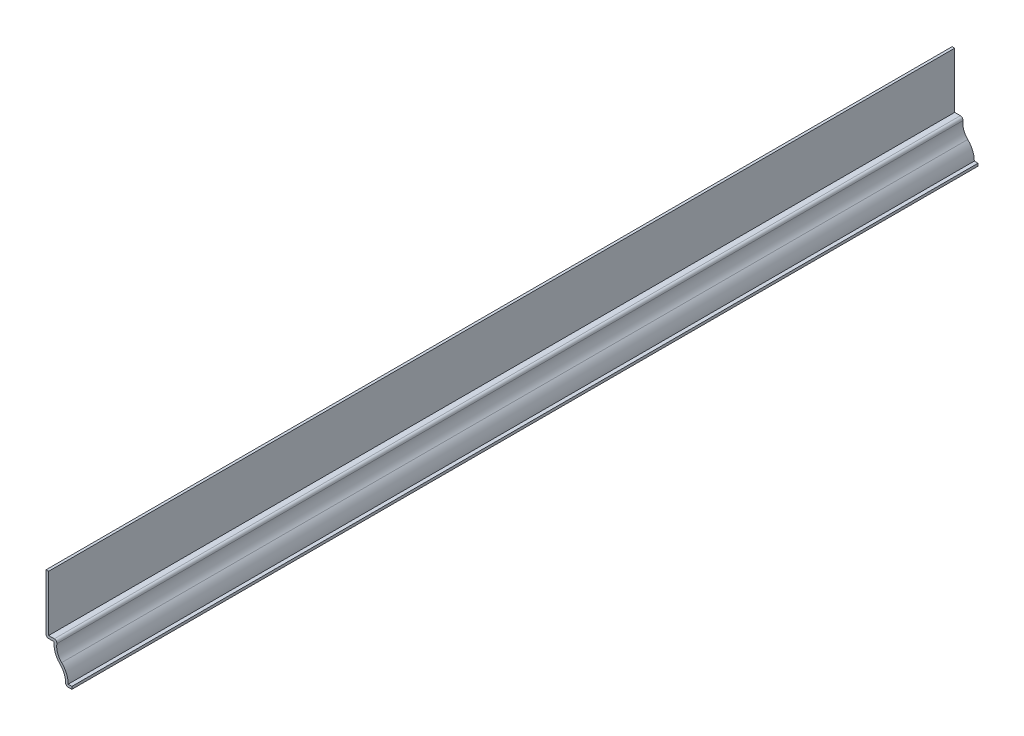
from build123d import *

# Parameters (mm, degrees)
EXTRUDE_THIN1_DEPTH = 444.5
FILLET1_R           = 1.27


with BuildPart() as part:
    # Sketch1 → Extrude-Thin1 (new body)
    with BuildSketch(Plane.XY):
        with BuildLine():
            Line((0, 0), (-3.175, 0))
            ThreePointArc((-3.175, 0), (-3.594278481, 4.295332119), (-5.909507538, 7.9375))
            ThreePointArc((-5.909507538, 7.9375), (-8.224736594, 11.579667881), (-8.644015075, 15.875))
            Line((-8.644015075, 15.875), (-12.7, 15.875))
            Line((-12.7, 15.875), (-12.7, 44.45))
            Line((-12.7, 44.45), (-11.43, 44.45))
            Line((-11.43, 44.45), (-11.43, 17.145))
            Line((-11.43, 17.145), (-7.048306528, 17.145))
            ThreePointArc((-7.048306528, 17.145), (-7.232980949, 12.705393558), (-5.025332022, 8.849165321))
            ThreePointArc((-5.025332022, 8.849165321), (-2.652667269, 5.384979729), (-1.817765075, 1.27))
            Line((-1.817765075, 1.27), (0, 1.27))
            Line((0, 1.27), (0, 0))
        make_face()
    extrude(amount=-EXTRUDE_THIN1_DEPTH)

    # Fillet1
    fillet1_edges = [part.edges().sort_by_distance(p)[0] for p in [
        (-7.048306528, 17.145, -222.25),
        (-3.175, 0, -222.25),
        (-12.7, 15.875, -222.25),
    ]]
    fillet(fillet1_edges, radius=FILLET1_R)


solid = part.part
